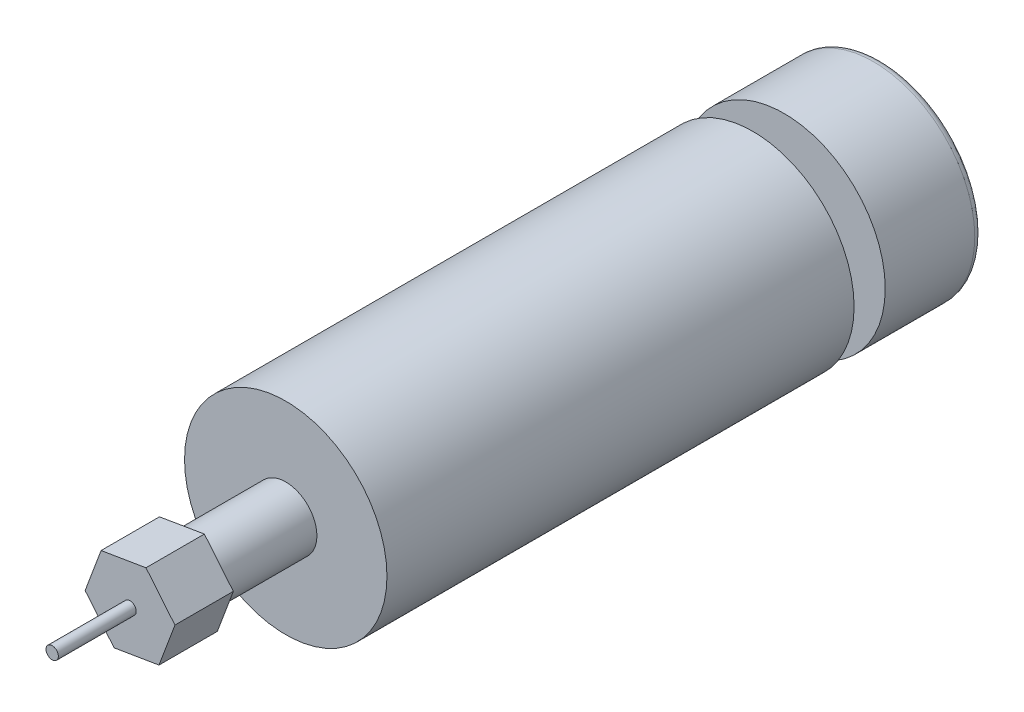
from build123d import *

# Parameters (mm, degrees)
SKETCH_1_R      = 26
EXTRUDE_1_DEPTH = 120
EXTRUDE_START   = 8
SKETCH_2_R      = 26
EXTRUDE_2_DEPTH = 25
FILLET_1_R      = 2
SKETCH_3_R      = 8
EXTRUDE_3_DEPTH = 40
EXTRUDE_4_DEPTH = 15
SKETCH_5_R      = 1.5875
EXTRUDE_5_DEPTH = 20
SKETCH_7_R      = 4
EXTRUDE_6_DEPTH = 6


with BuildPart() as part:
    # Эскиз1 → Бобышка-Вытянуть1 (new body)
    with BuildSketch(Plane.XY):
        Circle(SKETCH_1_R)
    extrude(amount=EXTRUDE_1_DEPTH)

    # Эскиз3 → Бобышка-Вытянуть3 (add)
    with BuildSketch(Plane.XY.offset(120)):
        Circle(SKETCH_3_R)
    extrude(amount=EXTRUDE_3_DEPTH)

    # Эскиз4 → Бобышка-Вытянуть4 (add)
    with BuildSketch(Plane.XY.offset(160)):
        Polygon((11.534146379, 1.930154149), (4.095510664, 10.95394085), (-7.438635716, 9.023786701), (-11.534146379, -1.930154149), (-4.095510664, -10.95394085), (7.438635716, -9.023786701), align=None)
    extrude(amount=-EXTRUDE_4_DEPTH)

    # Эскиз5 → Бобышка-Вытянуть5 (add)
    with BuildSketch(Plane(origin=(0, 0, 160), x_dir=(-1, 0, 0), z_dir=(0, 0, -1))):
        Circle(SKETCH_5_R)
    extrude(amount=-EXTRUDE_5_DEPTH)

    # Эскиз7 → Бобышка-Вытянуть6 (add)
    with BuildSketch(Plane(origin=(0, 0, 0), x_dir=(-1, 0, 0), z_dir=(0, 0, -1))):
        Circle(SKETCH_7_R)
    extrude(amount=EXTRUDE_6_DEPTH)


with BuildPart() as body_2:
    # Эскиз2 → Бобышка-Вытянуть2 (new body)
    with BuildSketch(Plane(origin=(0, 0, 0), x_dir=(-1, 0, 0), z_dir=(0, 0, -1)).offset(EXTRUDE_START)):
        Circle(SKETCH_2_R)
    extrude(amount=EXTRUDE_2_DEPTH)

    # Скругление1
    fillet_1_edges = [body_2.edges().sort_by_distance(p)[0] for p in [
        (26, 0, -33),
    ]]
    fillet(fillet_1_edges, radius=FILLET_1_R)


solid = Compound([part.part, body_2.part])
